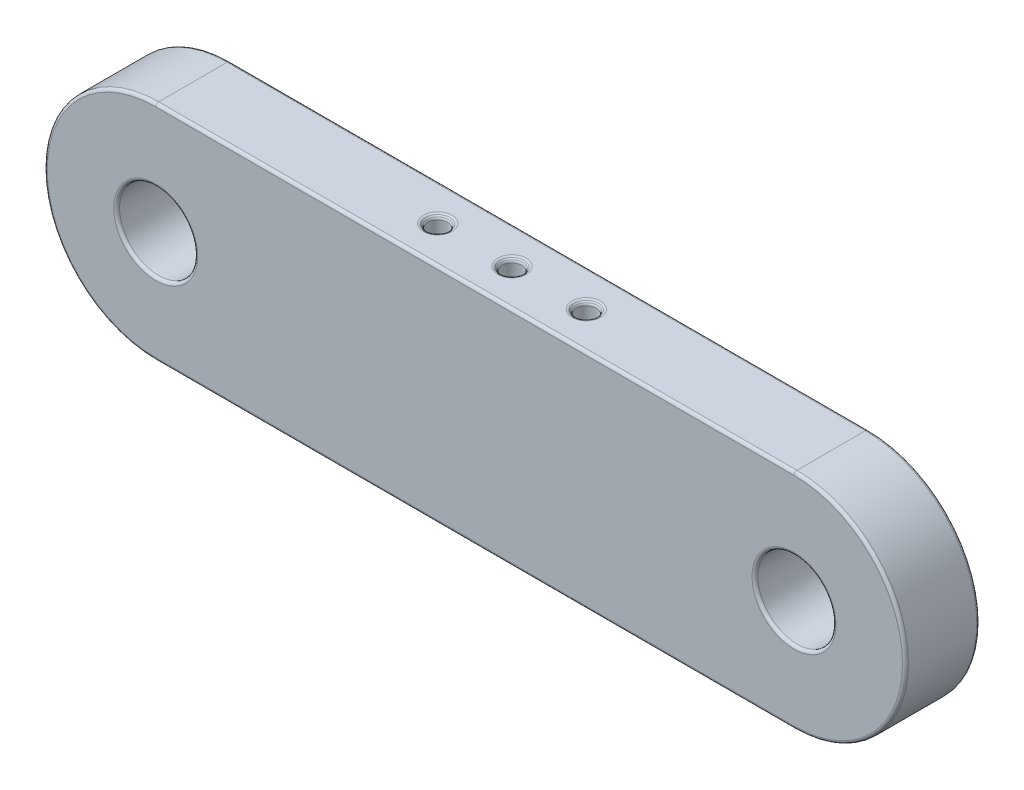
from build123d import *

# Parameters (mm, degrees)
SKETCH1_R           = 5.25
BOSS_EXTRUDE1_DEPTH = 10
CUT_EXTRUDE1_REACH  = 32
SKETCH2_R           = 1.35
CHAMFER1_SIZE       = 0.4
FILLET1_R           = 0.4


with BuildPart() as part:
    # Sketch1 → Boss-Extrude1 (new body)
    with BuildSketch(Plane.XY):
        with BuildLine():
            Line((-42.95, 15), (42.95, 15))
            ThreePointArc((42.95, 15), (57.95, 0), (42.95, -15))
            Line((42.95, -15), (-42.95, -15))
            ThreePointArc((-42.95, -15), (-57.95, 0), (-42.95, 15))
        make_face()
        with Locations((-42.95, 0)):
            Circle(SKETCH1_R, mode=Mode.SUBTRACT)
        with Locations((42.95, 0)):
            Circle(SKETCH1_R, mode=Mode.SUBTRACT)
    extrude(amount=BOSS_EXTRUDE1_DEPTH)

    # Sketch2 → Cut-Extrude1 (cut, up to next)
    with BuildSketch(Plane(origin=(0, 15, 0), x_dir=(1, 0, 0), z_dir=(0, 1, 0)), mode=Mode.PRIVATE) as cut_extrude1_sk1:
        with Locations((10, -5)):
            Circle(SKETCH2_R)
    cut_extrude1_tool1 = extrude(cut_extrude1_sk1.sketch, amount=-CUT_EXTRUDE1_REACH, mode=Mode.PRIVATE) & part.part
    add(cut_extrude1_tool1.solids().sort_by_distance((10, 15, 5))[0], mode=Mode.SUBTRACT)
    # Sketch2 → Cut-Extrude1 (cut, up to next)
    with BuildSketch(Plane(origin=(0, 15, 0), x_dir=(1, 0, 0), z_dir=(0, 1, 0)), mode=Mode.PRIVATE) as cut_extrude1_sk2:
        with Locations((0, -5)):
            Circle(SKETCH2_R)
    cut_extrude1_tool2 = extrude(cut_extrude1_sk2.sketch, amount=-CUT_EXTRUDE1_REACH, mode=Mode.PRIVATE) & part.part
    add(cut_extrude1_tool2.solids().sort_by_distance((0, 15, 5))[0], mode=Mode.SUBTRACT)
    # Sketch2 → Cut-Extrude1 (cut, up to next)
    with BuildSketch(Plane(origin=(0, 15, 0), x_dir=(1, 0, 0), z_dir=(0, 1, 0)), mode=Mode.PRIVATE) as cut_extrude1_sk3:
        with Locations((-10, -5)):
            Circle(SKETCH2_R)
    cut_extrude1_tool3 = extrude(cut_extrude1_sk3.sketch, amount=-CUT_EXTRUDE1_REACH, mode=Mode.PRIVATE) & part.part
    add(cut_extrude1_tool3.solids().sort_by_distance((-10, 15, 5))[0], mode=Mode.SUBTRACT)

    # Chamfer1
    chamfer1_edges = [part.edges().sort_by_distance(p)[0] for p in [
        (8.65, 15, 5),
        (8.65, -15, 5),
        (-1.35, 15, 5),
        (-1.35, -15, 5),
        (-11.35, 15, 5),
        (-11.35, -15, 5),
    ]]
    chamfer(chamfer1_edges, length=CHAMFER1_SIZE)

    # Fillet1
    fillet1_edges = [part.edges().sort_by_distance(p)[0] for p in [
        (-48.2, 0, 0),
        (-48.2, 0, 10),
        (57.95, 0, 10),
        (37.7, 0, 0),
        (37.7, 0, 10),
        (0, 15, 10),
        (-11.35, 14.6, 5),
        (-11.35, -14.6, 5),
        (8.25, -15, 5),
        (-1.75, -15, 5),
        (-11.75, -15, 5),
        (-1.35, 14.6, 5),
        (-1.35, -14.6, 5),
        (8.65, 14.6, 5),
        (8.65, -14.6, 5),
        (-11.75, 15, 5),
        (-1.75, 15, 5),
        (8.25, 15, 5),
        (-57.95, 0, 10),
        (0, 15, 0),
        (57.95, 0, 0),
        (0, -15, 0),
        (-57.95, 0, 0),
        (0, -15, 10),
    ]]
    fillet(fillet1_edges, radius=FILLET1_R)


solid = part.part
